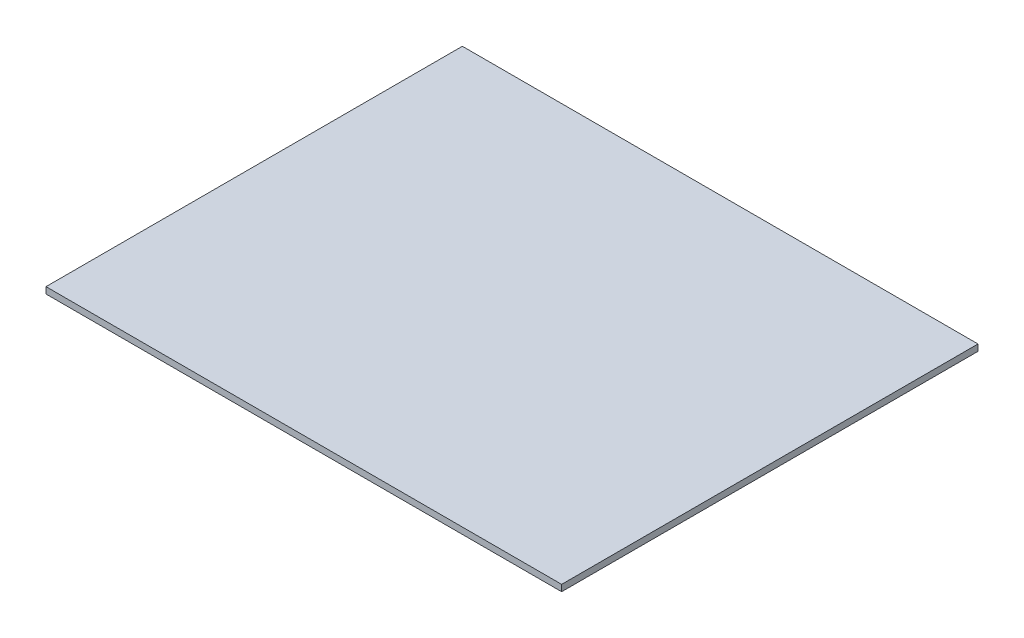
from build123d import *

# Parameters (mm, degrees)
SKETCH1_W           = 125
SKETCH1_H           = 94
SKETCH1_W_2         = 121
SKETCH1_H_2         = 52
MAIN_DEPTH          = 10
MAINFRONTFACE_START = 10
SKETCH1_4_W         = 161
SKETCH1_4_H         = 130
SKETCH1_4_W_2       = 125
SKETCH1_4_H_2       = 94
SKETCH1_4_W_3       = 121
SKETCH1_4_H_3       = 52
MAINFRONTFACE_DEPTH = 2
SKETCH5_R           = 3.5
NOTCH_DEPTH         = 4.2
SKETCH11_W          = 2
SKETCH11_H          = 6
WIREHOLES_DEPTH     = 10


with BuildPart() as part:
    # Sketch1 → Main (new body)
    with BuildSketch(Plane(origin=(0, 0, 0), x_dir=(1, 0, 0), z_dir=(0, 1, 0))):
        Rectangle(SKETCH1_W, SKETCH1_H)
        with Locations((0, -19)):
            Rectangle(SKETCH1_W_2, SKETCH1_H_2, mode=Mode.SUBTRACT)
    extrude(amount=MAIN_DEPTH)

    # Sketch5 → Notch (add)
    with BuildSketch(Plane.XZ):
        with Locations(Location((-50, -35, 0), (0, 0, 90))):
            Circle(SKETCH5_R)
    notch = extrude(amount=NOTCH_DEPTH)

    # Sketch8 one side → ActualNotch (revolve)
    with BuildSketch(Plane.XY.offset(-35)):
        with BuildLine():
            Line((-50, -7.058571571), (-50, -4.2))
            Line((-50, -4.2), (-57, -4.2))
            ThreePointArc((-57, -4.2), (-53.780589618, -6.316386764), (-50, -7.058571571))
        make_face()
    actualnotch = revolve(axis=Axis((-50, -8.4, -35), (0, 1, 0)))

    # Mirror1: Notch, ActualNotch across plane
    add(notch.mirror(Plane(origin=(0, 0, 0), x_dir=(0, 0, 1), z_dir=(1, 0, 0))))
    add(actualnotch.mirror(Plane(origin=(0, 0, 0), x_dir=(0, 0, 1), z_dir=(1, 0, 0))))

    # Sketch11 → WireHoles (cut)
    with BuildSketch(Plane.XZ):
        with Locations((-61.5, 42)):
            Rectangle(SKETCH11_W, SKETCH11_H)
        with Locations((61.5, 42)):
            Rectangle(SKETCH11_W, SKETCH11_H)
    extrude(amount=-WIREHOLES_DEPTH, mode=Mode.SUBTRACT)


with BuildPart() as body_2:
    # Sketch1_4 → MainFrontFace (new body)
    with BuildSketch(Plane(origin=(0, 0, 0), x_dir=(1, 0, 0), z_dir=(0, 1, 0)).offset(MAINFRONTFACE_START)):
        Rectangle(SKETCH1_4_W, SKETCH1_4_H)
        Rectangle(SKETCH1_4_W_2, SKETCH1_4_H_2, mode=Mode.SUBTRACT)
        Rectangle(SKETCH1_4_W_2, SKETCH1_4_H_2)
        with Locations((0, -19)):
            Rectangle(SKETCH1_4_W_3, SKETCH1_4_H_3, mode=Mode.SUBTRACT)
        with Locations((0, -19)):
            Rectangle(SKETCH1_4_W_3, SKETCH1_4_H_3)
    extrude(amount=MAINFRONTFACE_DEPTH)


with BuildPart() as wireholes_piece_1:
    # of the separate pieces the step leaves, piece 1, a body of its own (wireholes_pieces)
    add(part.part.solids().sort_by_distance((57, -4.2, -35))[0])


with BuildPart() as wireholes_piece_2:
    # of the separate pieces the step leaves, piece 2, a body of its own (wireholes_pieces)
    add(part.part.solids().sort_by_distance((62.5, 0, 47))[0])


solid = Compound([body_2.part, wireholes_piece_1.part, wireholes_piece_2.part])
